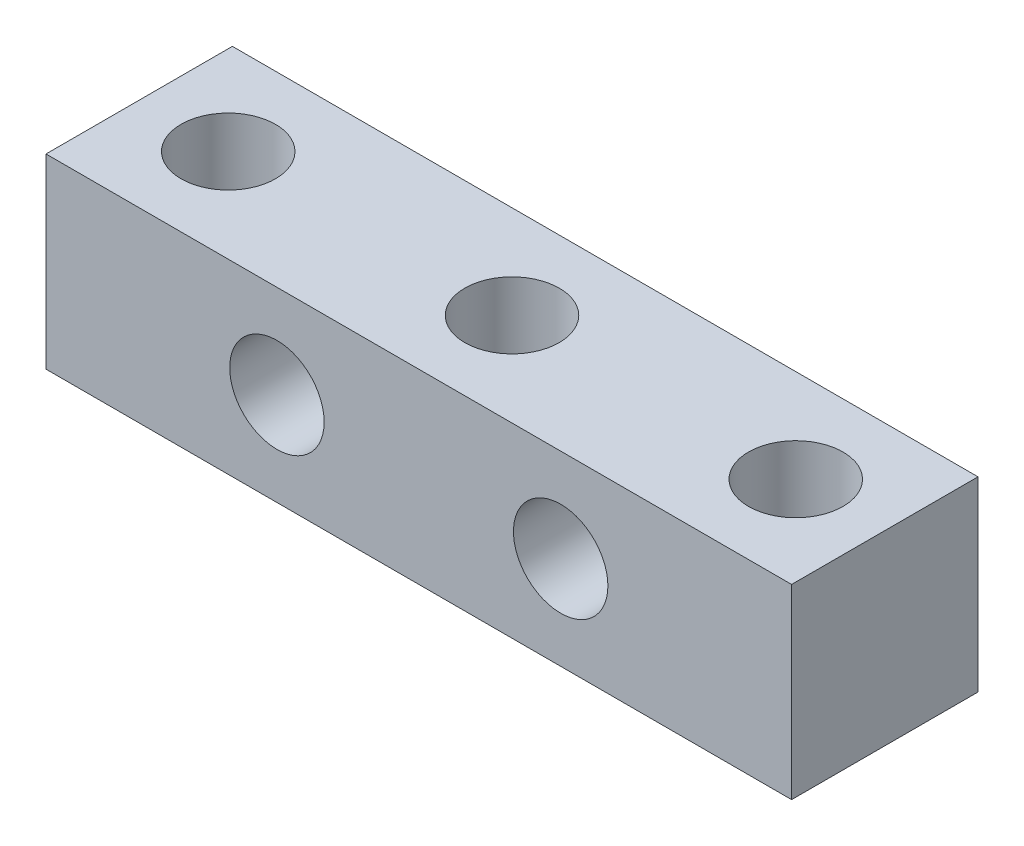
from build123d import *

# Parameters (mm, degrees)
SKETCH1_W              = 9.525
SKETCH1_H              = 9.525
BOSS_EXTRUDE1_DEPTH    = 38.1
F_10_24_TAPPED_HOLE1_D = 4.826
F_10_24_TAPPED_HOLE2_D = 4.826


with BuildPart() as part:
    # Sketch1 → Boss-Extrude1 (new body)
    with BuildSketch(Plane(origin=(0, 0, 0), x_dir=(0, 0, -1), z_dir=(1, 0, 0))):
        Rectangle(SKETCH1_W, SKETCH1_H)
    extrude(amount=BOSS_EXTRUDE1_DEPTH)

    # #10-24 Tapped Hole1 (through all)
    with Locations(Plane(origin=(0, 4.7625, 0), x_dir=(1, 0, 0), z_dir=(0, 1, 0))):
        with Locations((4.55, 0), (19.05, 0), (33.55, 0)):
            Hole(F_10_24_TAPPED_HOLE1_D / 2)

    # #10-24 Tapped Hole2 (through all)
    with Locations(Plane.XY.offset(4.7625)):
        with Locations((11.8, 0), (26.3, 0)):
            Hole(F_10_24_TAPPED_HOLE2_D / 2)


solid = part.part
